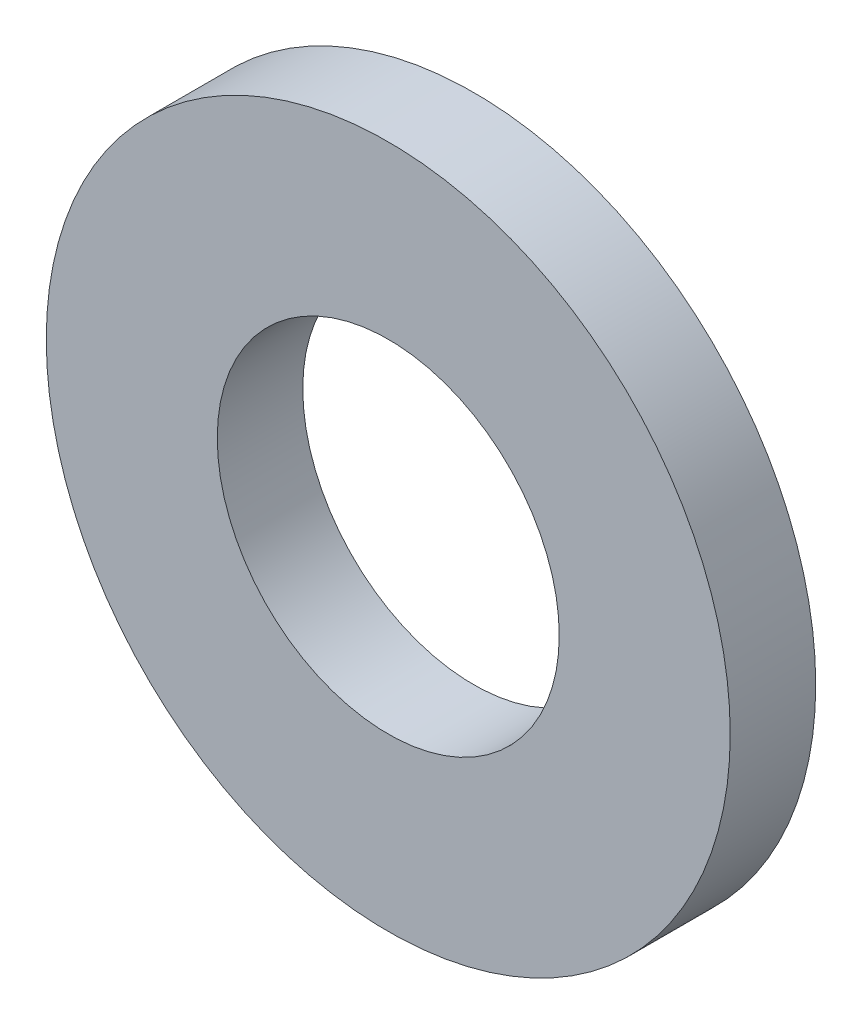
from build123d import *

# Parameters (mm, degrees)
SKETCH_1_R      = 4
SKETCH_1_R_2    = 2
EXTRUDE_1_DEPTH = 1


with BuildPart() as part:
    # 스케치1 → 보스-돌출1 (new body)
    with BuildSketch(Plane.XY):
        Circle(SKETCH_1_R)
        Circle(SKETCH_1_R_2, mode=Mode.SUBTRACT)
    extrude(amount=EXTRUDE_1_DEPTH)


solid = part.part
